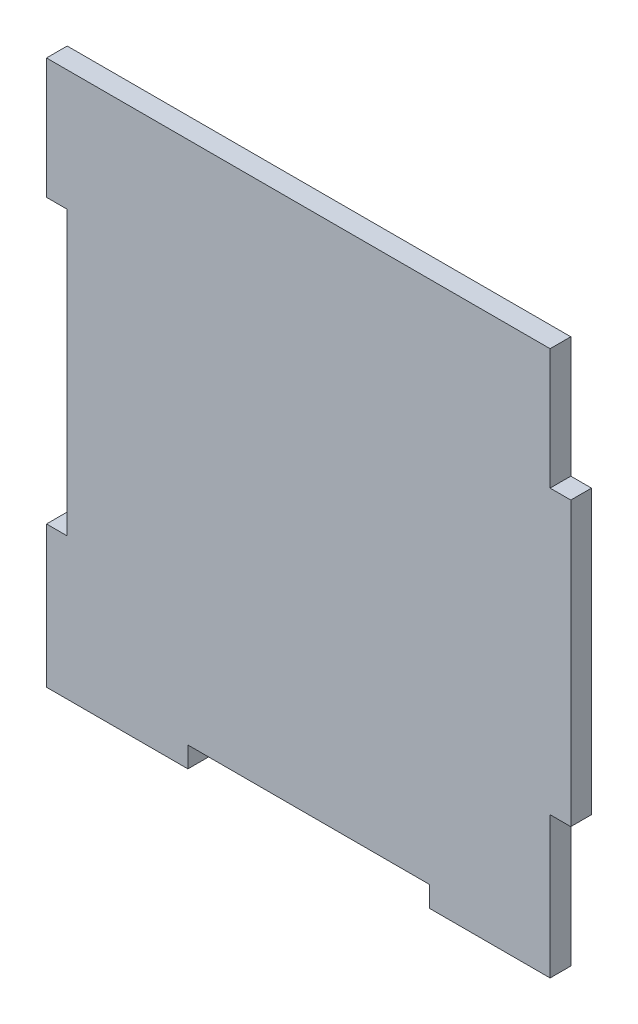
from build123d import *

# Parameters (mm, degrees)
BOSS_EXTRUDE1_DEPTH = 3


with BuildPart() as part:
    # Sketch1 → Boss-Extrude1 (new body)
    with BuildSketch(Plane.XY):
        Polygon((-35, 38), (-17.5, 38), (17.5, 38), (35, 38), (35, 20.5), (38, 20.5), (38, -20.5), (35, -20.5), (35, -38), (35, -41), (17.5, -41), (17.5, -38), (-17.5, -38), (-17.5, -41), (-35, -41), (-38, -41), (-38, -38), (-38, -20.5), (-35, -20.5), (-35, 20.5), (-38, 20.5), (-38, 38), align=None)
    extrude(amount=BOSS_EXTRUDE1_DEPTH)


solid = part.part
